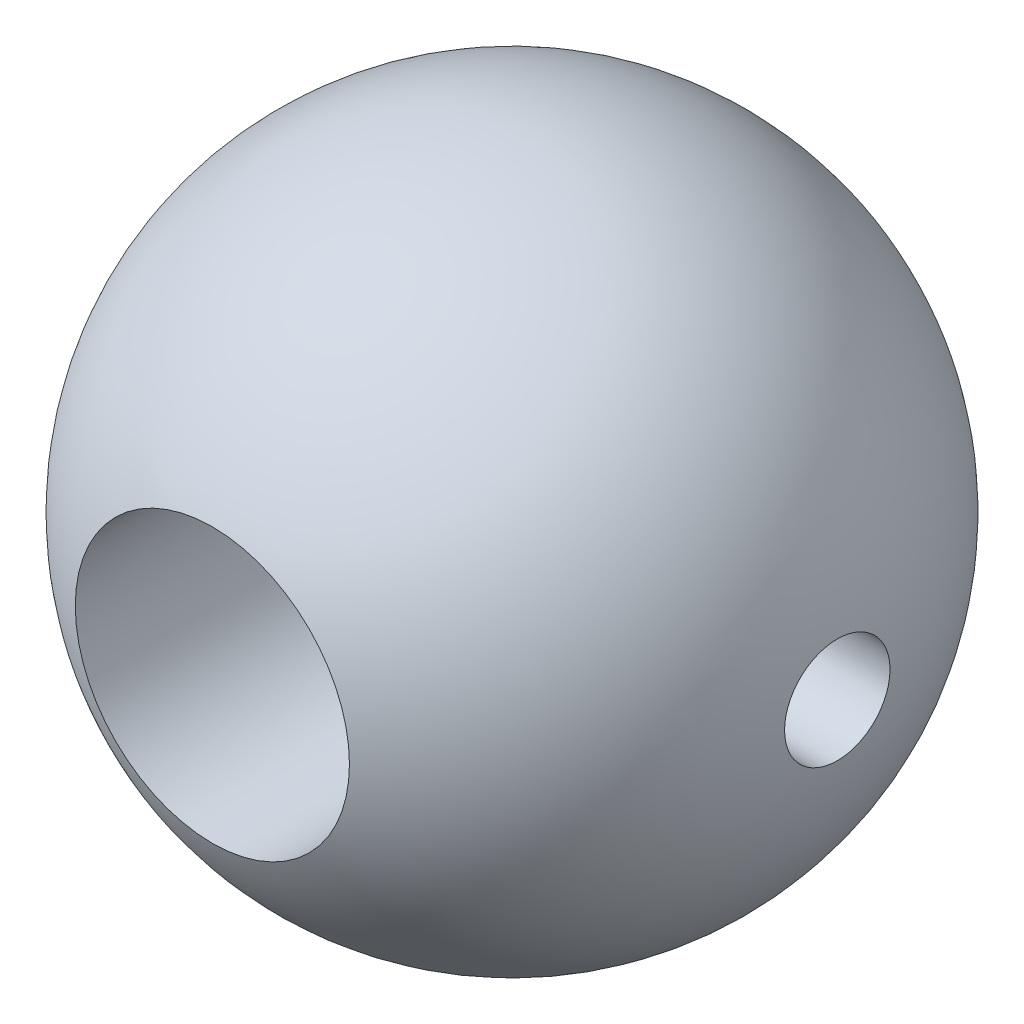
from build123d import *

# Parameters (mm, degrees)
SKETCH2_W = 31.354447878
SKETCH2_H = 1.524


with BuildPart() as part:
    # Sketch1 → Revolve1 (revolve)
    with BuildSketch(Plane(origin=(0, 0, 0), x_dir=(1, 0, 0), z_dir=(0, 1, 0))):
        with BuildLine():
            Line((3.9624, 8.661697942), (3.9624, -8.661697942))
            ThreePointArc((3.9624, -8.661697942), (9.525, 0), (3.9624, 8.661697942))
        make_face()
    revolve(axis=Axis((0, 0, 16.172180697), (0, 0, -1)))

    # Sketch2 → Cut-Revolve1 (revolve, cut)
    with BuildSketch(Plane(origin=(0, 0, 0), x_dir=(1, 0, 0), z_dir=(0, 1, 0))):
        with Locations((-1.564140393, 0.762)):
            Rectangle(SKETCH2_W, SKETCH2_H)
    revolve(axis=Axis((14.113083546, 0, 0), (-1, 0, 0)), mode=Mode.SUBTRACT)


solid = part.part
